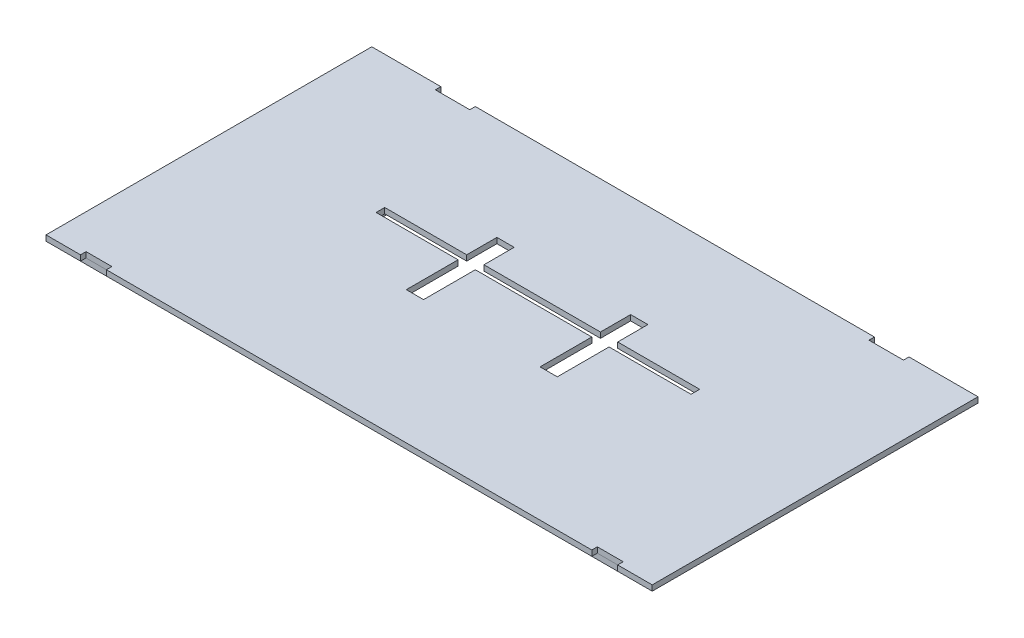
from build123d import *

# Parameters (mm, degrees)
SKETCH1_W           = 231.775
SKETCH1_H           = 6.35
BOSS_EXTRUDE1_DEPTH = 4.064
SKETCH2_W           = 12.7
SKETCH2_H           = 66.675
CUT_EXTRUDE1_DEPTH  = 5.064
BOSS_EXTRUDE2_DEPTH = 4.064


with BuildPart() as part:
    # Sketch1 → Boss-Extrude1 (new body)
    with BuildSketch(Plane(origin=(0, 0, 0), x_dir=(1, 0, 0), z_dir=(0, 1, 0))):
        Polygon((-223.0755, -150.123783392), (-197.6755, -150.123783392), (-197.6755, -146.059783392), (-178.6255, -146.059783392), (-178.6255, -150.123783392), (178.6255, -150.123783392), (178.6255, -146.059783392), (197.6755, -146.059783392), (197.6755, -150.123783392), (223.0755, -150.123783392), (223.0755, 89.652216608), (172.2755, 89.652216608), (172.2755, 85.588216608), (146.8755, 85.588216608), (146.8755, 89.652216608), (-146.8755, 89.652216608), (-146.8755, 85.588216608), (-172.2755, 85.588216608), (-172.2755, 89.652216608), (-223.0755, 89.652216608), align=None)
        with Locations((0, -11.185783392)):
            Rectangle(SKETCH1_W, SKETCH1_H, mode=Mode.SUBTRACT)
    extrude(amount=BOSS_EXTRUDE1_DEPTH)

    # Sketch2 → Cut-Extrude1 (cut, through all)
    with BuildSketch(Plane(origin=(0, 4.064, 0), x_dir=(1, 0, 0), z_dir=(0, 1, 0))):
        with Locations((49.2125, -19.123283392)):
            Rectangle(SKETCH2_W, SKETCH2_H)
        with Locations((-49.2125, -19.123283392)):
            Rectangle(SKETCH2_W, SKETCH2_H)
    extrude(amount=-CUT_EXTRUDE1_DEPTH, mode=Mode.SUBTRACT)


with BuildPart() as body_2:
    # Sketch3 → Boss-Extrude2 (new body)
    with BuildSketch(Plane.XZ):
        Polygon((93.1545, -7.991216608), (93.1545, -85.588216608), (219.0115, -85.588216608), (219.0115, 146.059783392), (93.1545, 146.059783392), (93.1545, 46.237783392), (118.5545, 46.237783392), (118.5545, -7.991216608), align=None)
    extrude(amount=BOSS_EXTRUDE2_DEPTH)


with BuildPart() as body_3:
    # Mirror1: mirrored copy
    add(body_2.part.mirror(Plane(origin=(0, 0, 0), x_dir=(0, 0, 1), z_dir=(1, 0, 0))))


solid = Compound([part.part, body_2.part, body_3.part])
